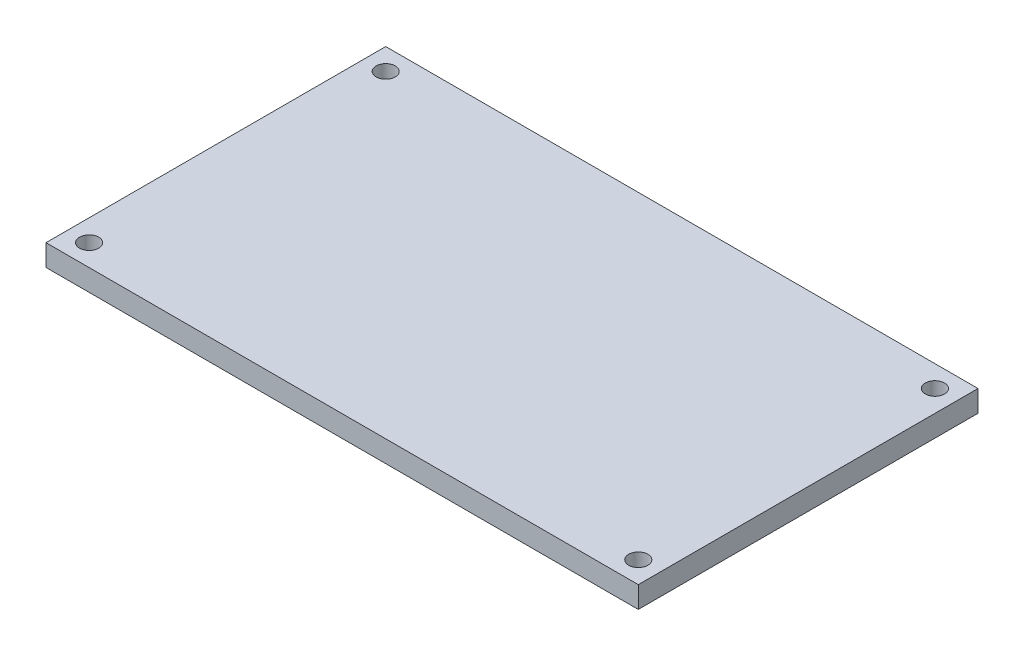
from build123d import *

# Parameters (mm, degrees)
SKETCH1_W           = 87.47
SKETCH1_H           = 50.17
BOSS_EXTRUDE1_DEPTH = 3.175
SKETCH2_R           = 1.415
CUT_EXTRUDE1_DEPTH  = 4.175


with BuildPart() as part:
    # Sketch1 → Boss-Extrude1 (new body)
    with BuildSketch(Plane(origin=(0, 0, 0), x_dir=(1, 0, 0), z_dir=(0, 1, 0))):
        Rectangle(SKETCH1_W, SKETCH1_H)
    extrude(amount=BOSS_EXTRUDE1_DEPTH)

    # Sketch2 → Cut-Extrude1 (cut, through all)
    with BuildSketch(Plane(origin=(0, 3.175, 0), x_dir=(1, 0, 0), z_dir=(0, 1, 0))):
        with Locations((-40.553019485, -21.903019485)):
            Circle(SKETCH2_R)
        with Locations((40.553019485, -21.903019485)):
            Circle(SKETCH2_R)
        with Locations((40.553019485, 21.903019485)):
            Circle(SKETCH2_R)
        with Locations((-40.553019485, 21.903019485)):
            Circle(SKETCH2_R)
    extrude(amount=-CUT_EXTRUDE1_DEPTH, mode=Mode.SUBTRACT)


solid = part.part
